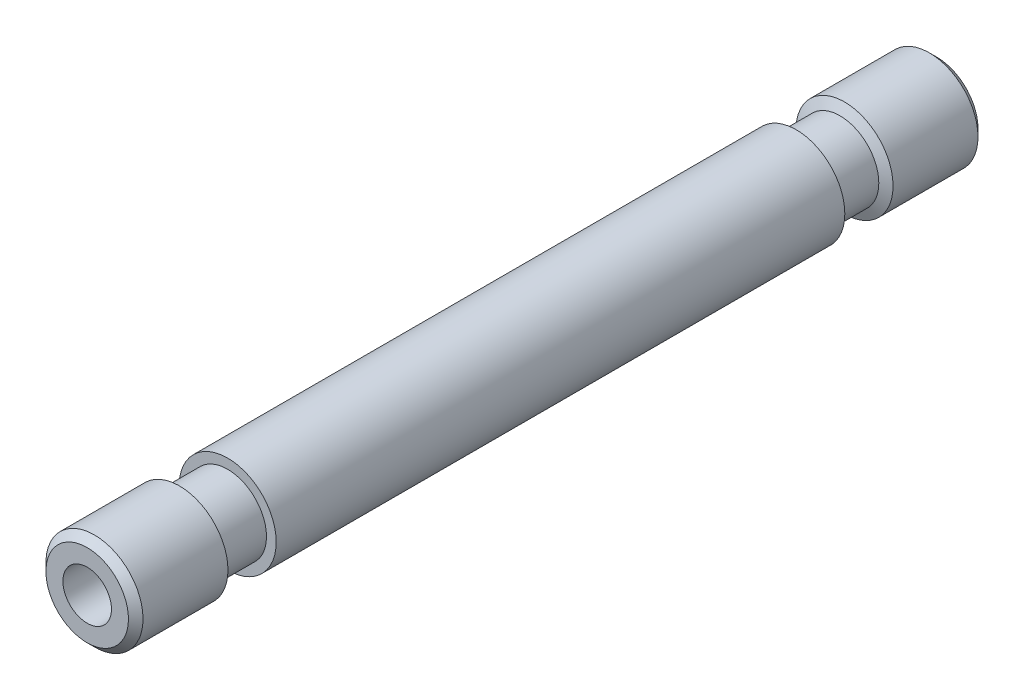
from build123d import *


with BuildPart() as part:
    # Sketch1 → Revolve1 (revolve)
    with BuildSketch(Plane(origin=(0, 0, 0), x_dir=(0, 0, -1), z_dir=(1, 0, 0))):
        Polygon((0, 1), (35, 1), (35, 1.7), (34.7, 2), (31.2, 2), (31.013476937, 1.6), (29.213476937, 1.6), (29.213476937, 2), (5.786523063, 2), (5.786523063, 1.6), (3.986523063, 1.6), (3.8, 2), (0.3, 2), (0, 1.7), align=None)
    revolve(axis=Axis((0, 0, -35), (0, 0, 1)))


solid = part.part
